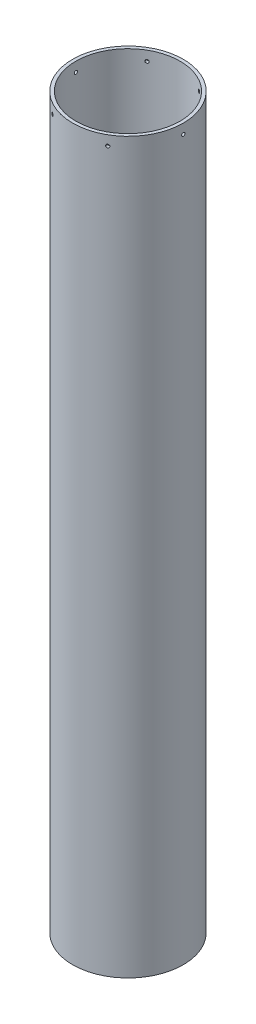
from build123d import *

# Parameters (mm, degrees)
SKETCH1_R           = 53.975
SKETCH1_R_2         = 50.8
BOSS_EXTRUDE1_DEPTH = 711.2
SKETCH2_R           = 1.5875
CUT_EXTRUDE1_DEPTH  = 54.975
CIRPATTERN1_COUNT   = 3


with BuildPart() as part:
    # Sketch1 → Boss-Extrude1 (new body)
    with BuildSketch(Plane(origin=(0, 0, 0), x_dir=(1, 0, 0), z_dir=(0, 1, 0))):
        Circle(SKETCH1_R)
        Circle(SKETCH1_R_2, mode=Mode.SUBTRACT)
    extrude(amount=BOSS_EXTRUDE1_DEPTH)

    # Sketch2 → Cut-Extrude1 (cut, symmetric)
    with BuildSketch(Plane(origin=(0, 0, 0), x_dir=(0, 0, -1), z_dir=(1, 0, 0))):
        with Locations((0, 701.675)):
            Circle(SKETCH2_R)
    cut_extrude1 = extrude(amount=CUT_EXTRUDE1_DEPTH, both=True, mode=Mode.SUBTRACT)

    # CirPattern1: Cut-Extrude1 ×3 about axis
    cirpattern1_axis = Axis((0, 711.2, 0), (0, 1, 0))
    for i in range(1, CIRPATTERN1_COUNT):
        add(cut_extrude1.rotate(cirpattern1_axis, i * 360 / CIRPATTERN1_COUNT), mode=Mode.SUBTRACT)


solid = part.part
